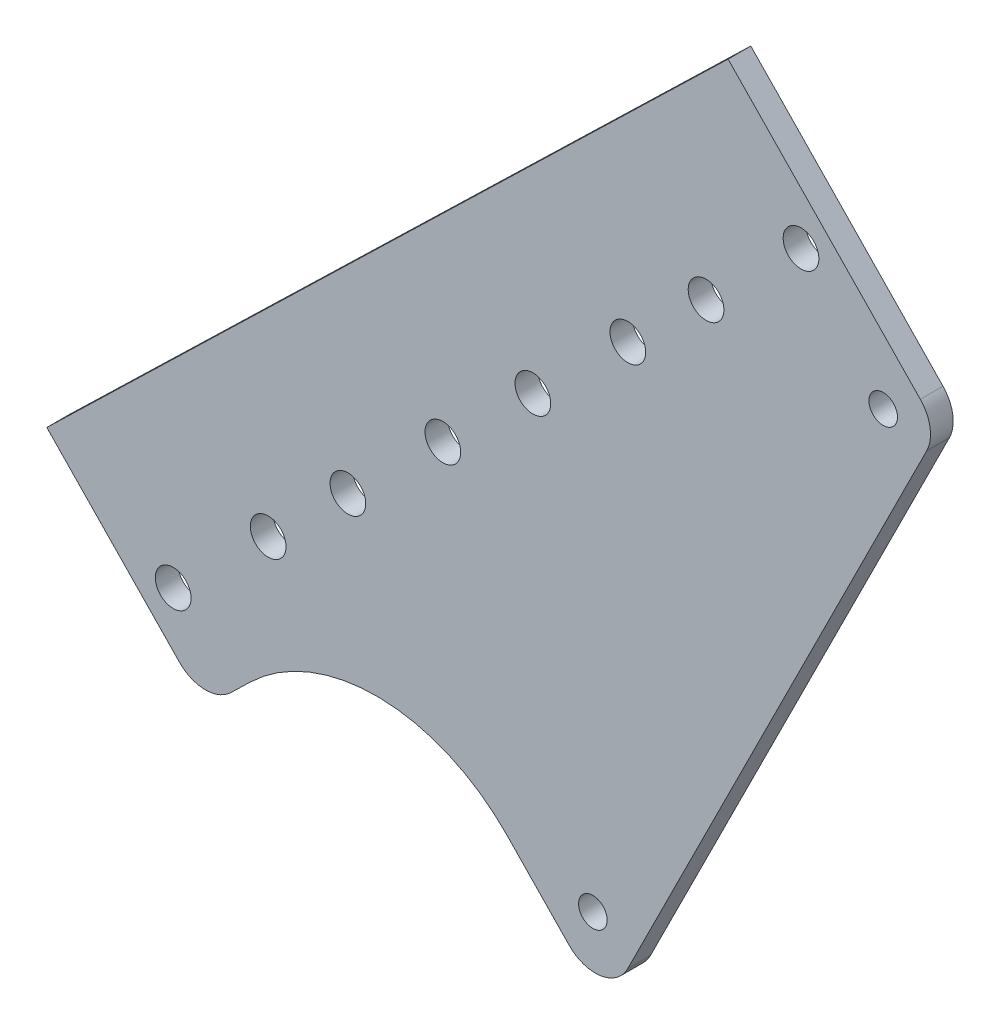
from build123d import *

# Parameters (mm, degrees)
SKETCH1_R           = 2
BOSS_EXTRUDE3_DEPTH = 3.175
SKETCH2_R           = 2.5
CUT_EXTRUDE1_DEPTH  = 4.175
BOSS_EXTRUDE4_DEPTH = 3.175
SKETCH4_R           = 2.5
CUT_EXTRUDE2_DEPTH  = 4.175
FILLET2_R           = 5.08
FILLET3_R           = 25.4
FILLET4_R           = 5.08


with BuildPart() as part:
    # Sketch1 → Boss-Extrude3 (new body)
    with BuildSketch(Plane.XY):
        Polygon((-12.628154113, 82.464660116), (-59.28812357, -10.855278797), (-112.74974727, 44.358551699), (-42.031929204, 112.83214508), (-23.460387201, 93.651920065), align=None)
        with Locations((-20.32, 81.28)):
            Circle(SKETCH1_R, mode=Mode.SUBTRACT)
        with Locations((-60.96, 0)):
            Circle(SKETCH1_R, mode=Mode.SUBTRACT)
    extrude(amount=BOSS_EXTRUDE3_DEPTH)

    # Sketch2 → Cut-Extrude1 (cut, through all)
    with BuildSketch(Plane(origin=(0, 0, 0), x_dir=(-1, 0, 0), z_dir=(0, 0, -1))):
        with Locations((95.243542319, 33.581465441)):
            Circle(SKETCH2_R)
        with Locations((31.824813554, 94.987605576)):
            Circle(SKETCH2_R)
        with Locations((81.952877746, 46.450351765)):
            Circle(SKETCH2_R)
        with Locations((45.115478127, 82.118719252)):
            Circle(SKETCH2_R)
        with Locations((56.064112078, 71.517539384)):
            Circle(SKETCH2_R)
        with Locations((69.354776651, 58.64865306)):
            Circle(SKETCH2_R)
    extrude(amount=-CUT_EXTRUDE1_DEPTH, mode=Mode.SUBTRACT)

    # Sketch3 → Boss-Extrude4 (add)
    with BuildSketch(Plane(origin=(0, 0, 0), x_dir=(-1, 0, 0), z_dir=(0, 0, -1))):
        Polygon((112.74974727, 44.358551699), (137.38417366, 20.505896995), (115.298382267, -2.30375707), (90.663955877, 21.548897635), align=None)
    extrude(amount=-BOSS_EXTRUDE4_DEPTH)

    # Sketch4 → Cut-Extrude2 (cut, through all)
    with BuildSketch(Plane(origin=(0, 0, 0), x_dir=(-1, 0, 0), z_dir=(0, 0, -1))):
        with Locations((106.404826903, 22.774383392)):
            Circle(SKETCH4_R)
        with Locations((119.695491476, 9.905497068)):
            Circle(SKETCH4_R)
    extrude(amount=-CUT_EXTRUDE2_DEPTH, mode=Mode.SUBTRACT)

    # Fillet2
    fillet2_edges = [part.edges().sort_by_distance(p)[0] for p in [
        (-59.28812357, -10.855278797, 1.5875),
        (-12.628154113, 82.464660116, 1.5875),
    ]]
    fillet(fillet2_edges, radius=FILLET2_R)

    # Fillet3
    fillet3_edges = [part.edges().sort_by_distance(p)[0] for p in [
        (-90.663955877, 21.548897635, 1.5875),
    ]]
    fillet(fillet3_edges, radius=FILLET3_R)

    # Fillet4
    fillet4_edges = [part.edges().sort_by_distance(p)[0] for p in [
        (-115.298382267, -2.30375707, 1.5875),
    ]]
    fillet(fillet4_edges, radius=FILLET4_R)


solid = part.part
